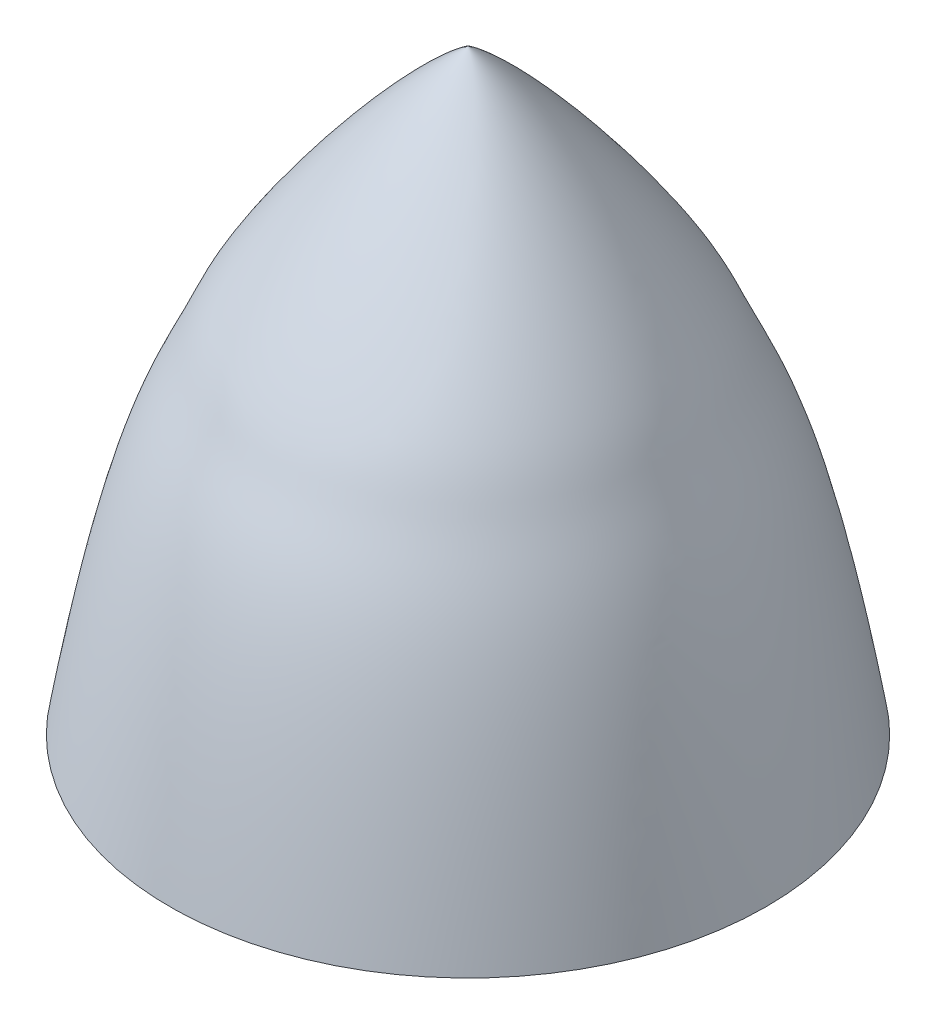
from build123d import *


with BuildPart() as part:
    # 스케치1 → 회전1 (revolve)
    with BuildSketch(Plane.XY):
        with BuildLine():
            Line((0, 0), (0, 19))
            add(Edge.make_bspline(
                [(0, 19), (1.877897337, 17.685082128), (5.585232017, 12.972849138), (7.266574424, 8.907099573), (8.237916209, 7.541915343), (9.5, 0)],
                knots=[0, 0, 0, 0, 0.402099285, 0.502099285, 1, 1, 1, 1], degree=3))
            Line((9.5, 0), (0, 0))
        make_face()
    revolve(axis=Axis((0, 0, 0), (0, 1, 0)))


solid = part.part
